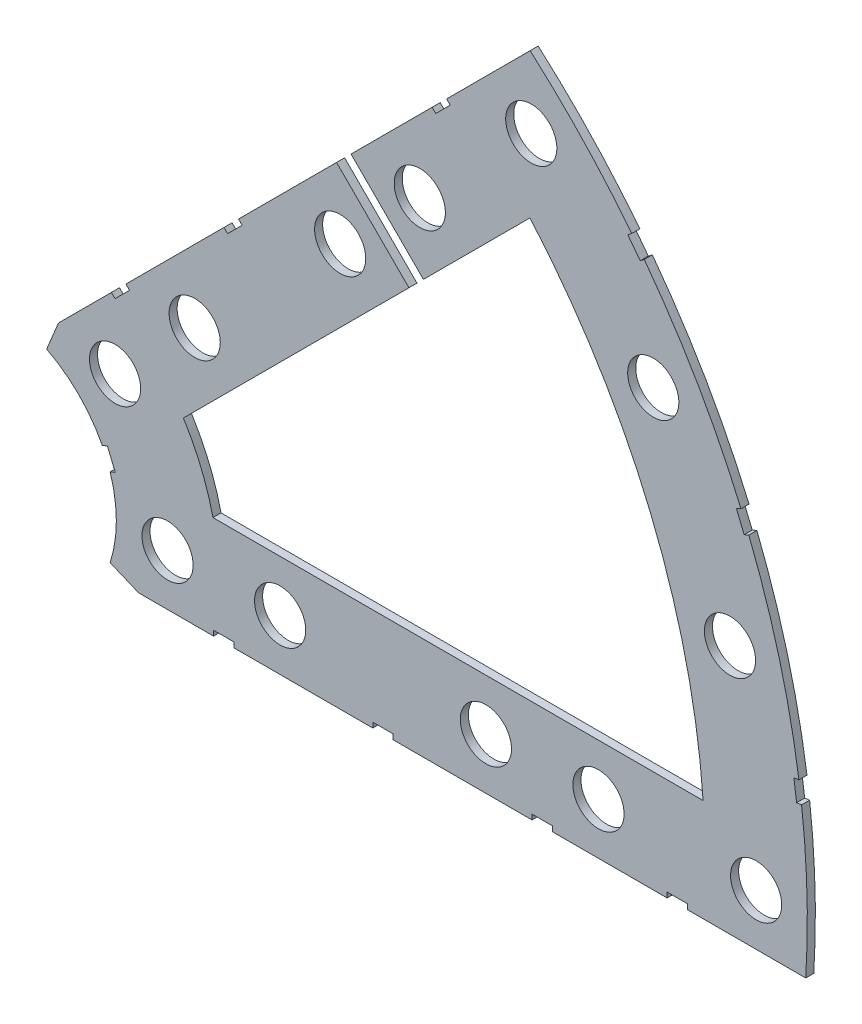
from build123d import *

# Parameters (mm, degrees)
BOSS_EXTRUDE1_DEPTH = 1
SKETCH2_R           = 3.175
CUT_EXTRUDE1_DEPTH  = 2
SKETCH3_W           = 2.54
SKETCH3_H           = 0.635
CUT_EXTRUDE2_DEPTH  = 2


with BuildPart() as part:
    # Sketch1 → Boss-Extrude1 (new body)
    with BuildSketch(Plane.XY):
        with BuildLine():
            Line((67.21146711, 76.191723231), (8.696654013, 17.676910134))
            Line((8.696654013, 17.676910134), (7.228954972, 14.133571205))
            ThreePointArc((7.228954972, 14.133571205), (14.666587579, 6.075099489), (15.105587123, -4.88230096))
            Line((15.105587123, -4.88230096), (18.648926052, -6.35))
            Line((18.648926052, -6.35), (101.401368334, -6.35))
            ThreePointArc((101.401368334, -6.35), (93.866160503, 38.880636728), (67.21146711, 76.191723231))
        make_face()
        with BuildLine():
            Line((88.672924278, 6.35), (27.86051193, 6.35))
            ThreePointArc((27.86051193, 6.35), (26.399857642, 10.93517908), (24.190484974, 15.210228852))
            Line((24.190484974, 15.210228852), (67.191354125, 58.211098004))
            ThreePointArc((67.191354125, 58.211098004), (82.13289044, 34.020557137), (88.672924278, 6.35))
        make_face(mode=Mode.SUBTRACT)
    extrude(amount=BOSS_EXTRUDE1_DEPTH)

    # Sketch2 → Cut-Extrude1 (cut, through all)
    with BuildSketch(Plane.XY.offset(1)):
        with Locations((22.225, 0)):
            Circle(SKETCH2_R)
        with Locations((36.195, 0)):
            Circle(SKETCH2_R)
        with Locations((61.722, 0)):
            Circle(SKETCH2_R)
        with Locations((75.692, 0)):
            Circle(SKETCH2_R)
        with Locations((95.25, 0)):
            Circle(SKETCH2_R)
        with Locations((15.715448212, 15.715448212)):
            Circle(SKETCH2_R)
        with Locations((25.593729945, 25.593729945)):
            Circle(SKETCH2_R)
        with Locations((43.644044748, 43.644044748)):
            Circle(SKETCH2_R)
        with Locations((53.522326482, 53.522326482)):
            Circle(SKETCH2_R)
        with Locations((92.004434954, 24.652514046)):
            Circle(SKETCH2_R)
        with Locations((82.48891971, 47.625)):
            Circle(SKETCH2_R)
        with Locations((67.351920908, 67.351920908)):
            Circle(SKETCH2_R)
    extrude(amount=-CUT_EXTRUDE1_DEPTH, mode=Mode.SUBTRACT)

    # Sketch3 → Cut-Extrude2 (cut, through all)
    with BuildSketch(Plane.XY.offset(1)):
        Polygon((15.266435406, 24.246691527), (17.06248663, 26.042742751), (17.511499436, 25.593729945), (15.715448212, 23.797678721), align=None)
        Polygon((43.195031942, 52.175288063), (44.991083167, 53.971339288), (53.971339288, 44.991083167), (52.175288063, 43.195031942), align=None)
        with Locations((29.21, -6.0325)):
            Rectangle(SKETCH3_W, SKETCH3_H)
        with Locations((68.707, -6.0325)):
            Rectangle(SKETCH3_W, SKETCH3_H)
        Polygon((29.230733674, 38.210989795), (31.026784898, 40.007041019), (31.475797704, 39.558028213), (29.67974648, 37.761976989), align=None)
        Polygon((56.845021246, 65.825277367), (55.048970022, 64.029226143), (55.497982828, 63.580213337), (57.294034052, 65.376264561), align=None)
        with Locations((48.9585, -6.0325)):
            Rectangle(SKETCH3_W, SKETCH3_H)
        with Locations((85.471, -6.0325)):
            Rectangle(SKETCH3_W, SKETCH3_H)
        Polygon((99.935462164, 14.437711971), (100.266998693, 11.919442024), (101.526133667, 12.085210288), (101.194597138, 14.603480236), align=None)
        Polygon((93.765504959, 37.464305742), (94.938831965, 37.950313702), (93.966816047, 40.296967714), (92.793489041, 39.810959755), align=None)
        Polygon((79.327792988, 62.471156422), (80.874047017, 60.456038938), (81.88160576, 61.229165953), (80.33535173, 63.244283437), align=None)
        Polygon((13.593916116, 7.005422516), (14.565932035, 4.658768503), (15.739259041, 5.144776462), (14.767243123, 7.491430475), align=None)
    extrude(amount=-CUT_EXTRUDE2_DEPTH, mode=Mode.SUBTRACT)


solid = part.part
